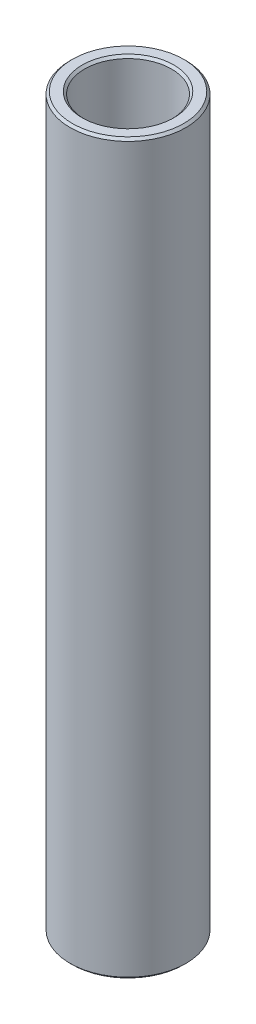
from build123d import *

# Parameters (mm, degrees)
SKETCH1_W     = 1.5875
SKETCH1_H     = 79.771875
CHAMFER1_SIZE = 0.254


with BuildPart() as part:
    # Sketch1 → Revolve1 (revolve)
    with BuildSketch(Plane.XY):
        with Locations((5.55625, 112.588304964)):
            Rectangle(SKETCH1_W, SKETCH1_H)
    revolve(axis=Axis((0, 63.177367464, 0), (0, 1, 0)))

    # Chamfer1
    chamfer1_edges = [part.edges().sort_by_distance(p)[0] for p in [
        (-6.35, 72.702367465, 0),
        (-6.349999995, 152.474242465, 0),
        (-4.762499995, 152.474242465, 0),
        (-4.7625, 72.702367464, 0),
    ]]
    chamfer(chamfer1_edges, length=CHAMFER1_SIZE)


solid = part.part
